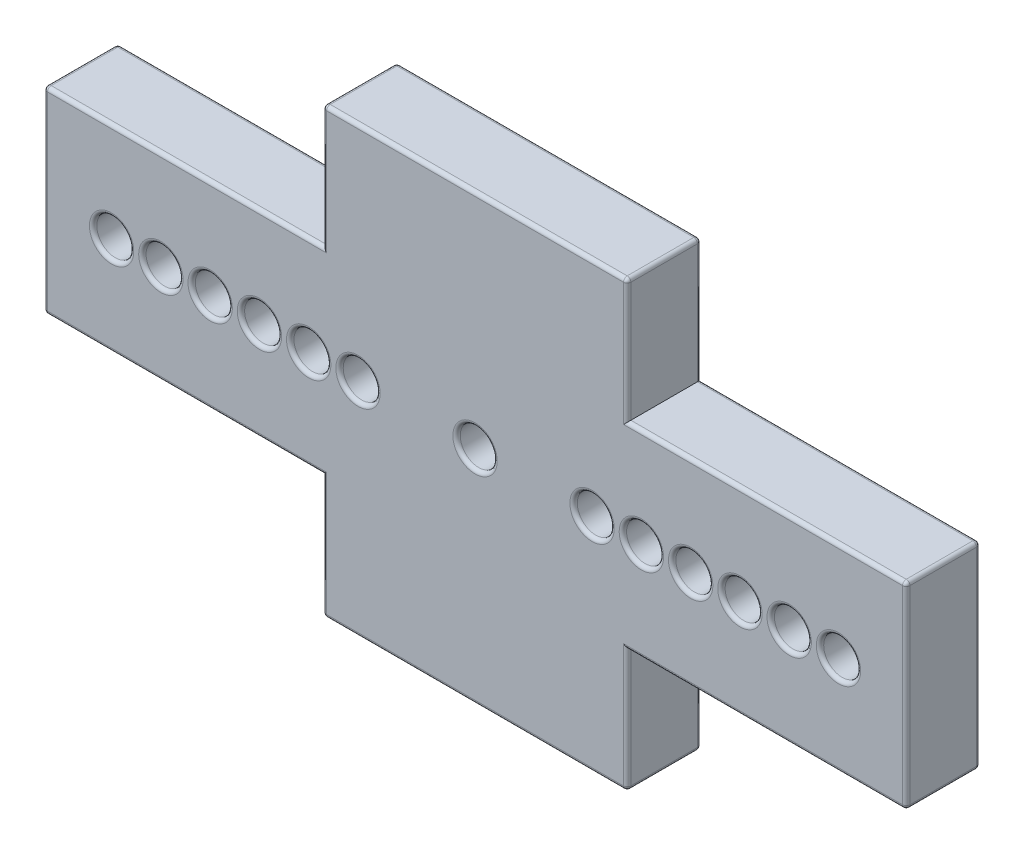
from build123d import *

# Parameters (mm, degrees)
SKETCH1_R           = 0.75
BOSS_EXTRUDE1_DEPTH = 1.5
SKETCH3_R           = 0.75
CUT_EXTRUDE1_DEPTH  = 4
FILLET1_R           = 0.15


with BuildPart() as part:
    # Sketch1 → Boss-Extrude1 (new body, symmetric)
    with BuildSketch(Plane.XY):
        Polygon((-17.5, 4), (-6.175, 4), (-6.175, 9), (6.175, 9), (6.175, 4), (17.5, 4), (17.5, -4), (6.175, -4), (6.175, -9), (-6.175, -9), (-6.175, -4), (-17.5, -4), align=None)
        Circle(SKETCH1_R, mode=Mode.SUBTRACT)
    extrude(amount=BOSS_EXTRUDE1_DEPTH, both=True)

    # Sketch3 → Cut-Extrude1 (cut, through all)
    with BuildSketch(Plane.XY.offset(1.5)):
        with Locations((-14.75, 0)):
            Circle(SKETCH3_R)
        with Locations((-12.75, 0)):
            Circle(SKETCH3_R)
        with Locations((-10.75, 0)):
            Circle(SKETCH3_R)
        with Locations((-8.75, 0)):
            Circle(SKETCH3_R)
        with Locations((-6.75, 0)):
            Circle(SKETCH3_R)
        with Locations((-4.75, 0)):
            Circle(SKETCH3_R)
    cut_extrude1 = extrude(amount=-CUT_EXTRUDE1_DEPTH, mode=Mode.SUBTRACT)

    # Mirror1: Cut-Extrude1 across plane
    add(cut_extrude1.mirror(Plane(origin=(0, 0, 0), x_dir=(0, 0, 1), z_dir=(1, 0, 0))), mode=Mode.SUBTRACT)

    # Fillet1
    fillet1_edges = [part.edges().sort_by_distance(p)[0] for p in [
        (11.8375, -4, -1.5),
        (6.175, -6.5, -1.5),
        (6.175, 6.5, 1.5),
        (0, -9, -1.5),
        (-6.175, -6.5, -1.5),
        (-11.8375, -4, -1.5),
        (-17.5, 0, -1.5),
        (-11.8375, 4, -1.5),
        (-6.175, 6.5, -1.5),
        (0, 9, -1.5),
        (6.175, 6.5, -1.5),
        (11.8375, 4, -1.5),
        (17.5, 0, -1.5),
        (0, 9, 1.5),
        (17.5, -4, 0),
        (6.175, -9, 0),
        (-6.175, 6.5, 1.5),
        (-6.175, -9, 0),
        (-17.5, -4, 0),
        (-17.5, 4, 0),
        (-6.175, 9, 0),
        (6.175, 9, 0),
        (17.5, 4, 0),
        (-11.8375, 4, 1.5),
        (-17.5, 0, 1.5),
        (-0.75, 0, -1.5),
        (-0.75, 0, 1.5),
        (-11.8375, -4, 1.5),
        (-6.175, -6.5, 1.5),
        (0, -9, 1.5),
        (6.175, -6.5, 1.5),
        (-15.5, 0, -1.5),
        (-15.5, 0, 1.5),
        (11.8375, -4, 1.5),
        (-13.5, 0, -1.5),
        (-13.5, 0, 1.5),
        (17.5, 0, 1.5),
        (-11.5, 0, -1.5),
        (-11.5, 0, 1.5),
        (-9.5, 0, -1.5),
        (-9.5, 0, 1.5),
        (-7.5, 0, -1.5),
        (-7.5, 0, 1.5),
        (-5.5, 0, -1.5),
        (-5.5, 0, 1.5),
        (15.5, 0, 1.5),
        (15.5, 0, -1.5),
        (13.5, 0, 1.5),
        (13.5, 0, -1.5),
        (11.5, 0, 1.5),
        (11.5, 0, -1.5),
        (9.5, 0, 1.5),
        (9.5, 0, -1.5),
        (7.5, 0, 1.5),
        (7.5, 0, -1.5),
        (5.5, 0, 1.5),
        (5.5, 0, -1.5),
        (11.8375, 4, 1.5),
    ]]
    fillet(fillet1_edges, radius=FILLET1_R)


solid = part.part
